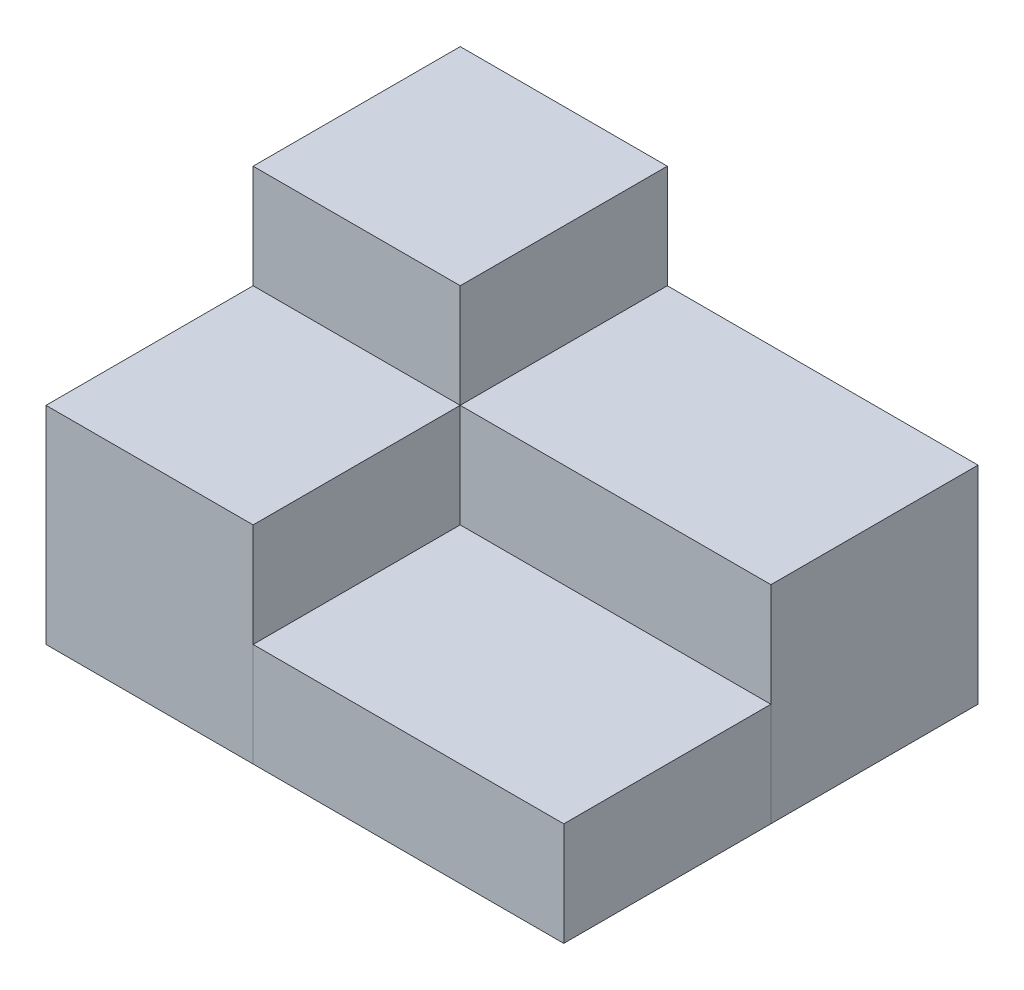
from build123d import *

# Parameters (mm, degrees)
SKETCH1_W             = 30
SKETCH1_H             = 20
BOSS_EXTRUDE1_DEPTH   = 20
SKETCH1_W_2           = 20
BOSS_EXTRUDE1_2_DEPTH = 20
SKETCH1_3_W           = 30
SKETCH1_3_H           = 20
BOSS_EXTRUDE3_DEPTH   = 10
SKETCH1_4_W           = 20
SKETCH1_4_H           = 20
BOSS_EXTRUDE4_DEPTH   = 30


with BuildPart() as part:
    # Sketch1 → Boss-Extrude1 (new body)
    with BuildSketch(Plane(origin=(0, 0, 0), x_dir=(1, 0, 0), z_dir=(0, 1, 0))):
        with Locations((35, 30)):
            Rectangle(SKETCH1_W, SKETCH1_H)
    extrude(amount=BOSS_EXTRUDE1_DEPTH)


with BuildPart() as body_2:
    # Sketch1 → Boss-Extrude1 2 (new body)
    with BuildSketch(Plane(origin=(0, 0, 0), x_dir=(1, 0, 0), z_dir=(0, 1, 0))):
        with Locations((10, 10)):
            Rectangle(SKETCH1_W_2, SKETCH1_H)
    extrude(amount=BOSS_EXTRUDE1_2_DEPTH)


with BuildPart() as body_3:
    # Sketch1_3 → Boss-Extrude3 (new body)
    with BuildSketch(Plane(origin=(0, 0, 0), x_dir=(1, 0, 0), z_dir=(0, 1, 0))):
        with Locations((35, 10)):
            Rectangle(SKETCH1_3_W, SKETCH1_3_H)
    extrude(amount=BOSS_EXTRUDE3_DEPTH)


with BuildPart() as body_4:
    # Sketch1_4 → Boss-Extrude4 (new body)
    with BuildSketch(Plane(origin=(0, 0, 0), x_dir=(1, 0, 0), z_dir=(0, 1, 0))):
        with Locations((10, 30)):
            Rectangle(SKETCH1_4_W, SKETCH1_4_H)
    extrude(amount=BOSS_EXTRUDE4_DEPTH)


solid = Compound([part.part, body_2.part, body_3.part, body_4.part])
